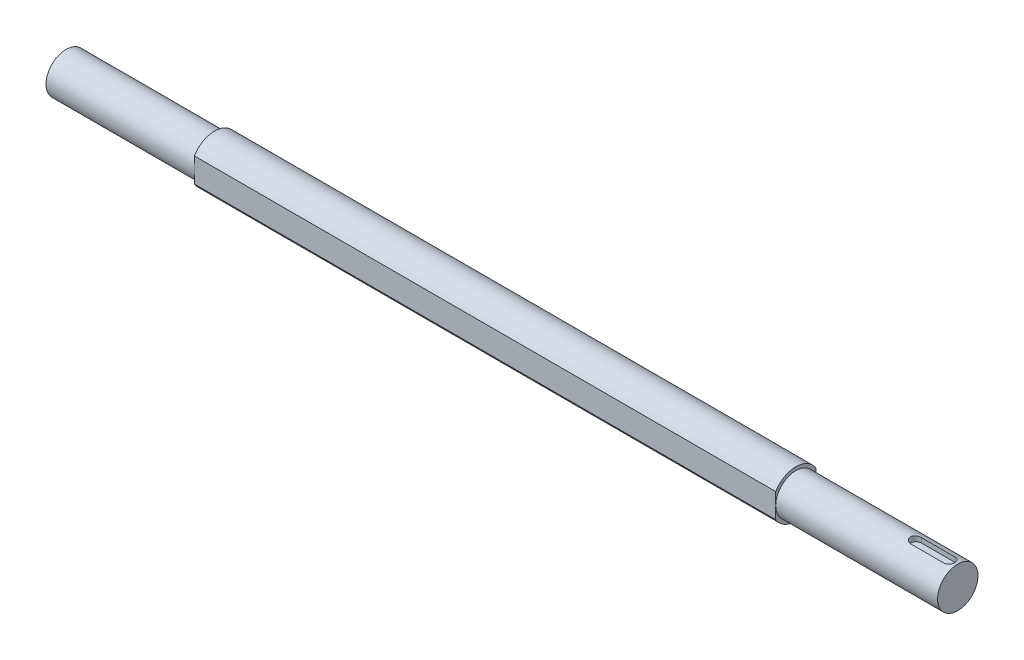
from build123d import *

# Parameters (mm, degrees)
KES_EKSTR_ZYON1_DEPTH = 431
KES_EKSTR_ZYON2_DEPTH = 4


with BuildPart() as part:
    # Çizim1 → Döndür1 (revolve)
    with BuildSketch(Plane.XY):
        Polygon((-330.5, 0), (330.5, 0), (330.5, 15), (210.5, 15), (210.5, 17.5), (-220.5, 17.5), (-220.5, 15), (-330.5, 15), align=None)
    revolve(axis=Axis((-330.5, 0, 0), (1, 0, 0)))

    # Çizim2 → Kes-Ekstrüzyon1 (cut)
    with BuildSketch(Plane.ZY.offset(220.5)):
        with BuildLine():
            Line((-15, 9.013878189), (-15, -9.013878189))
            ThreePointArc((-15, -9.013878189), (-17.5, 0), (-15, 9.013878189))
        make_face()
        with BuildLine():
            Line((15, 9.013878189), (15, -9.013878189))
            ThreePointArc((15, -9.013878189), (17.5, 0), (15, 9.013878189))
        make_face()
    extrude(amount=-KES_EKSTR_ZYON1_DEPTH, mode=Mode.SUBTRACT)

    # Çizim3 → Kes-Ekstrüzyon2 (cut)
    with BuildSketch(Plane(origin=(0, 15, 0), x_dir=(1, 0, 0), z_dir=(0, 1, 0))):
        with BuildLine():
            Line((324.5, -4), (299.5, -4))
            ThreePointArc((299.5, -4), (295.5, 0), (299.5, 4))
            Line((299.5, 4), (324.5, 4))
            ThreePointArc((324.5, 4), (328.5, 0), (324.5, -4))
        make_face()
    extrude(amount=-KES_EKSTR_ZYON2_DEPTH, mode=Mode.SUBTRACT)


solid = part.part
